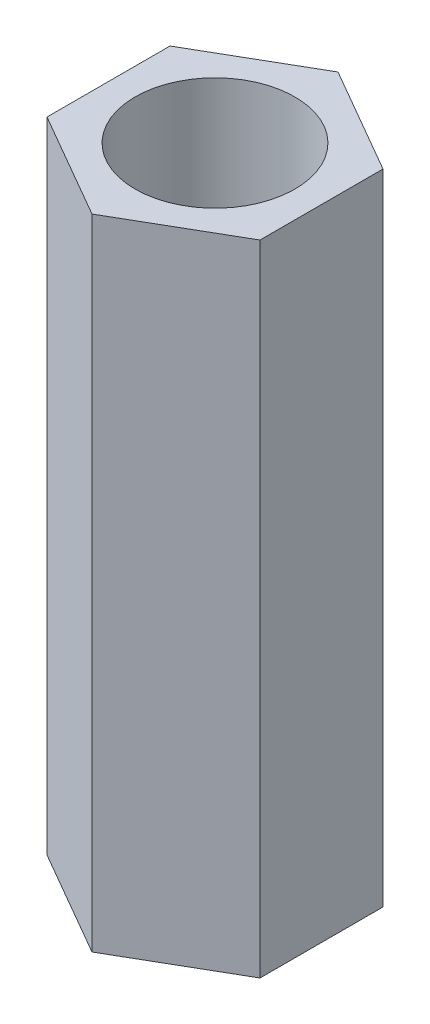
from build123d import *

# Parameters (mm, degrees)
SKETCH_1_R      = 1.5
EXTRUDE_1_DEPTH = 12


with BuildPart() as part:
    # 草图1 → 凸台-拉伸1 (new body)
    with BuildSketch(Plane(origin=(0, 0, 0), x_dir=(1, 0, 0), z_dir=(0, 1, 0))):
        Polygon((0, 2.309401077), (-2, 1.154700538), (-2, -1.154700538), (0, -2.309401077), (2, -1.154700538), (2, 1.154700538), align=None)
        Circle(SKETCH_1_R, mode=Mode.SUBTRACT)
    extrude(amount=EXTRUDE_1_DEPTH)


solid = part.part
